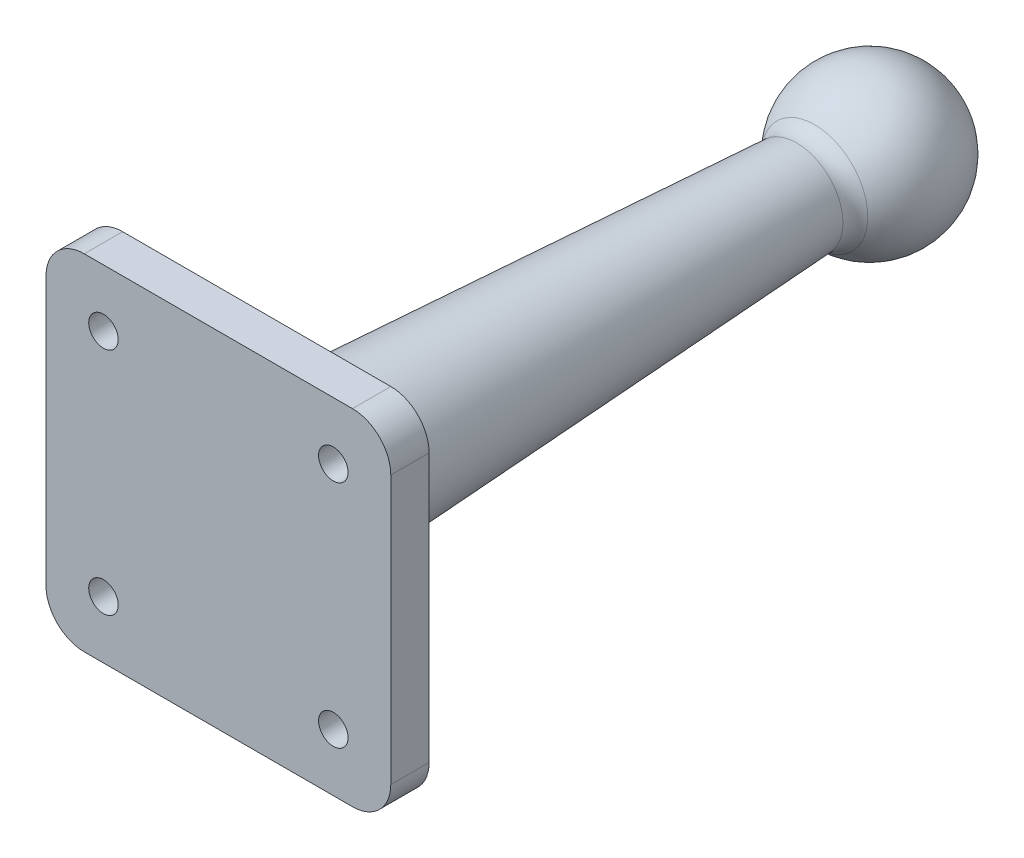
from build123d import *

# Parameters (mm, degrees)
SKETCH1_W           = 45
SKETCH1_H           = 45
BOSS_EXTRUDE1_DEPTH = 5
FILLET1_R           = 5
SKETCH4_R           = 1.925
CUT_EXTRUDE1_DEPTH  = 6
FILLET3_R           = 3
CHAMFER1_SIZE2      = 5.306388248
CHAMFER1_SIZE       = 5


with BuildPart() as part:
    # Sketch1 → Boss-Extrude1 (new body)
    with BuildSketch(Plane.XY):
        Rectangle(SKETCH1_W, SKETCH1_H)
    extrude(amount=BOSS_EXTRUDE1_DEPTH)

    # Fillet1
    fillet1_edges = [part.edges().sort_by_distance(p)[0] for p in [
        (22.5, -22.5, 2.5),
        (-22.5, -22.5, 2.5),
        (-22.5, 22.5, 2.5),
        (22.5, 22.5, 2.5),
    ]]
    fillet(fillet1_edges, radius=FILLET1_R)

    # Sketch2 → Revolve1 (revolve)
    with BuildSketch(Plane(origin=(0, 0, 0), x_dir=(1, 0, 0), z_dir=(0, 1, 0))):
        Polygon((10, 0), (5.5, 80), (0, 80), (0, 0), align=None)
    revolve(axis=Axis((0, 0, 0), (0, 0, -1)))

    # Sketch3 → Revolve2 (revolve)
    with BuildSketch(Plane(origin=(0, 0, 0), x_dir=(1, 0, 0), z_dir=(0, 1, 0))):
        with BuildLine():
            Line((0, 90), (0, 70))
            ThreePointArc((0, 70), (10, 80), (0, 90))
        make_face()
    revolve(axis=Axis((0, 0, -90), (0, 0, 1)))

    # Sketch4 → Cut-Extrude1 (cut, through all)
    with BuildSketch(Plane(origin=(0, 0, 0), x_dir=(-1, 0, 0), z_dir=(0, 0, -1))):
        with Locations((15, 15)):
            Circle(SKETCH4_R)
        with Locations((15, -15)):
            Circle(SKETCH4_R)
        with Locations((-15, -15)):
            Circle(SKETCH4_R)
        with Locations((-15, 15)):
            Circle(SKETCH4_R)
    extrude(amount=-CUT_EXTRUDE1_DEPTH, mode=Mode.SUBTRACT)

    # Fillet3
    fillet3_edges = [part.edges().sort_by_distance(p)[0] for p in [
        (-5.952011904, 0, -71.964232813),
    ]]
    fillet(fillet3_edges, radius=FILLET3_R)

    # Chamfer1
    chamfer1_edges = [part.edges().sort_by_distance(p)[0] for p in [
        (-10, 0, 0),
    ]]
    chamfer(chamfer1_edges, length=CHAMFER1_SIZE, length2=CHAMFER1_SIZE2)


solid = part.part
